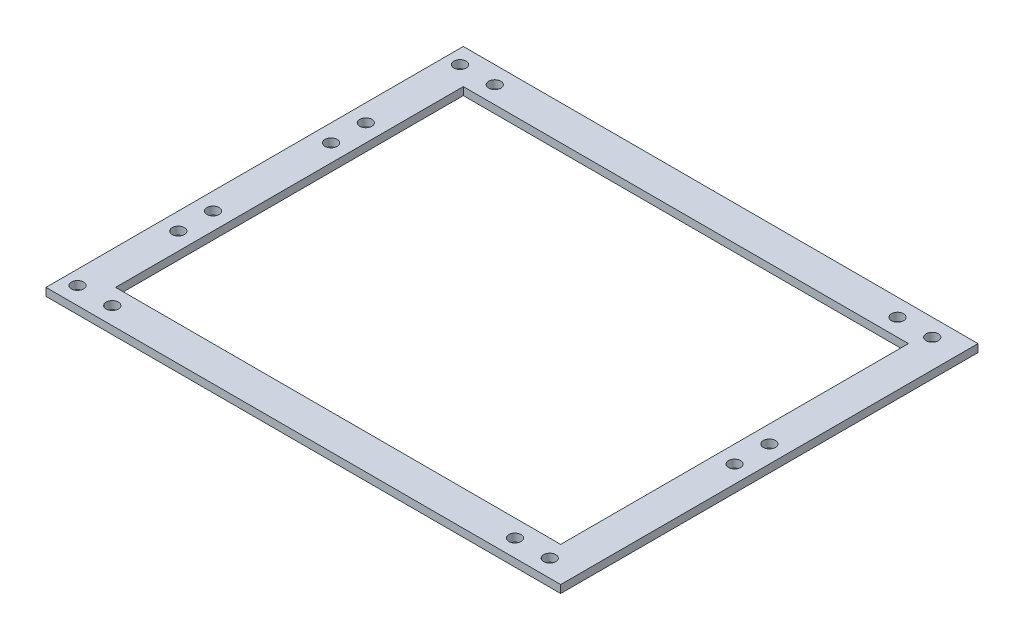
from build123d import *

# Parameters (mm, degrees)
SKETCH1_W           = 296
SKETCH1_H           = 240
SKETCH1_W_2         = 256
SKETCH1_H_2         = 200
BOSS_EXTRUDE1_DEPTH = 4.5
SKETCH2_R           = 3.5
CUT_EXTRUDE1_DEPTH  = 4.5
SKETCH3_R           = 3.5
CUT_EXTRUDE2_DEPTH  = 4.5
SKETCH4_R           = 3.5
CUT_EXTRUDE3_DEPTH  = 4.5
SKETCH5_R           = 3.5
CUT_EXTRUDE4_DEPTH  = 4.5


with BuildPart() as part:
    # Sketch1 → Boss-Extrude1 (new body)
    with BuildSketch(Plane(origin=(0, 0, 0), x_dir=(1, 0, 0), z_dir=(0, 1, 0))):
        Rectangle(SKETCH1_W, SKETCH1_H)
        Rectangle(SKETCH1_W_2, SKETCH1_H_2, mode=Mode.SUBTRACT)
    extrude(amount=BOSS_EXTRUDE1_DEPTH)

    # Sketch2 → Cut-Extrude1 (cut)
    with BuildSketch(Plane(origin=(0, 4.5, 0), x_dir=(1, 0, 0), z_dir=(0, 1, 0))):
        with Locations((-139.9, -110)):
            Circle(SKETCH2_R)
        with Locations((-119.9, -110)):
            Circle(SKETCH2_R)
    cut_extrude1 = extrude(amount=-CUT_EXTRUDE1_DEPTH, mode=Mode.SUBTRACT)

    # Mirror1: Cut-Extrude1 across plane
    add(cut_extrude1.mirror(Plane.XY), mode=Mode.SUBTRACT)

    # Sketch3 → Cut-Extrude2 (cut)
    with BuildSketch(Plane(origin=(0, 4.5, 0), x_dir=(1, 0, 0), z_dir=(0, 1, 0))):
        with Locations((131.7, -110)):
            Circle(SKETCH3_R)
        with Locations((111.7, -110)):
            Circle(SKETCH3_R)
    cut_extrude2 = extrude(amount=-CUT_EXTRUDE2_DEPTH, mode=Mode.SUBTRACT)

    # Mirror2: Cut-Extrude2 across plane
    add(cut_extrude2.mirror(Plane.XY), mode=Mode.SUBTRACT)

    # Sketch4 → Cut-Extrude3 (cut)
    with BuildSketch(Plane(origin=(0, 4.5, 0), x_dir=(1, 0, 0), z_dir=(0, 1, 0))):
        with Locations((138, 10)):
            Circle(SKETCH4_R)
        with Locations((138, -10)):
            Circle(SKETCH4_R)
    extrude(amount=-CUT_EXTRUDE3_DEPTH, mode=Mode.SUBTRACT)

    # Sketch5 → Cut-Extrude4 (cut)
    with BuildSketch(Plane(origin=(0, 4.5, 0), x_dir=(1, 0, 0), z_dir=(0, 1, 0))):
        with Locations((-138, 53.924043482)):
            Circle(SKETCH5_R)
        with Locations((-138, 33.924043482)):
            Circle(SKETCH5_R)
        with Locations((-138, -33.924043482)):
            Circle(SKETCH5_R)
        with Locations((-138, -53.924043482)):
            Circle(SKETCH5_R)
    extrude(amount=-CUT_EXTRUDE4_DEPTH, mode=Mode.SUBTRACT)


solid = part.part
